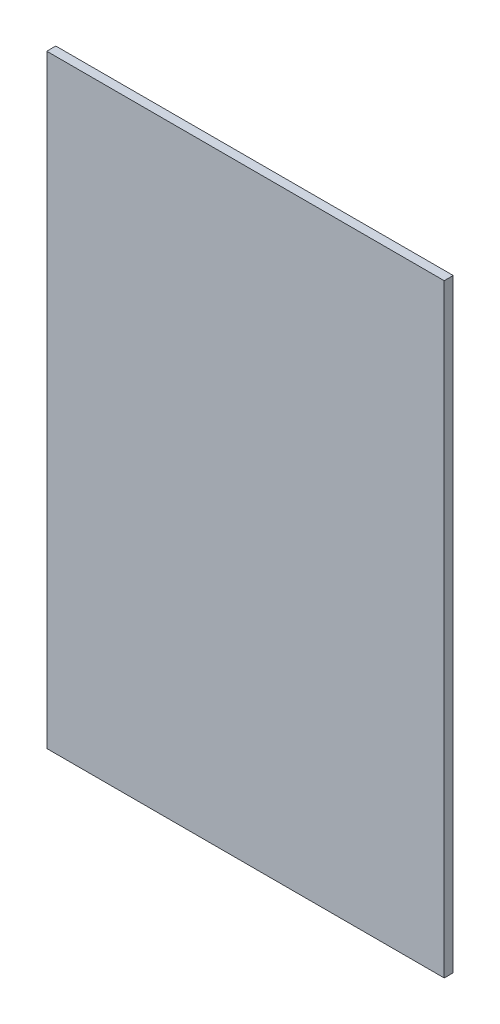
from build123d import *

# Parameters (mm, degrees)
SKETCH1_W      = 176.4
SKETCH1_H      = 268
EXTRUDE1_DEPTH = 4


with BuildPart() as part:
    # Sketch1 → Extrude1 (new body)
    with BuildSketch(Plane.XY):
        Rectangle(SKETCH1_W, SKETCH1_H)
    extrude(amount=EXTRUDE1_DEPTH)


solid = part.part
